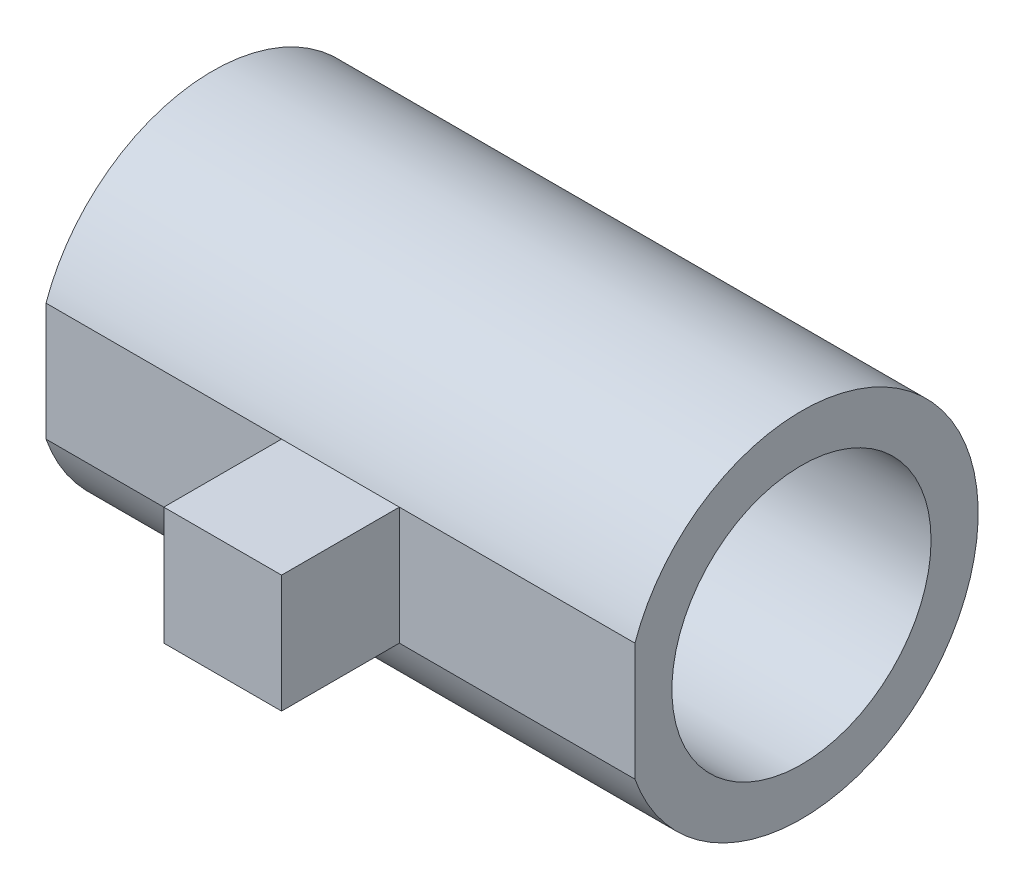
from build123d import *

# Parameters (mm, degrees)
SKETCH_1_R          = 15
SKETCH_1_R_2        = 11
EXTRUDE_1_DEPTH     = 50
SKETCH_2_W          = 10
SKETCH_2_H          = 10
EXTRUDE_2_DEPTH     = 50
SKETCH_3_W          = 20
SKETCH_3_H          = 10
CUT_EXTRUDE_1_DEPTH = 50


with BuildPart() as part:
    # 草图1 → 凸台-拉伸1 (new body)
    with BuildSketch(Plane(origin=(0, 0, 0), x_dir=(0, 0, -1), z_dir=(1, 0, 0))):
        Circle(SKETCH_1_R)
        Circle(SKETCH_1_R_2, mode=Mode.SUBTRACT)
    extrude(amount=EXTRUDE_1_DEPTH)

    # 草图2 → 凸台-拉伸2 (add)
    with BuildSketch(Plane.ZY):
        with Locations((19.142135624, 0)):
            Rectangle(SKETCH_2_W, SKETCH_2_H)
    extrude(amount=-EXTRUDE_2_DEPTH)

    # 草图3 → 切除-拉伸1 (cut)
    with BuildSketch(Plane(origin=(0, -5, 0), x_dir=(-1, 0, 0), z_dir=(0, -1, 0))):
        with Locations((-10, -19.142135624)):
            Rectangle(SKETCH_3_W, SKETCH_3_H)
        with Locations((-40, -19.142135624)):
            Rectangle(SKETCH_3_W, SKETCH_3_H)
    extrude(amount=-CUT_EXTRUDE_1_DEPTH, mode=Mode.SUBTRACT)


solid = part.part
